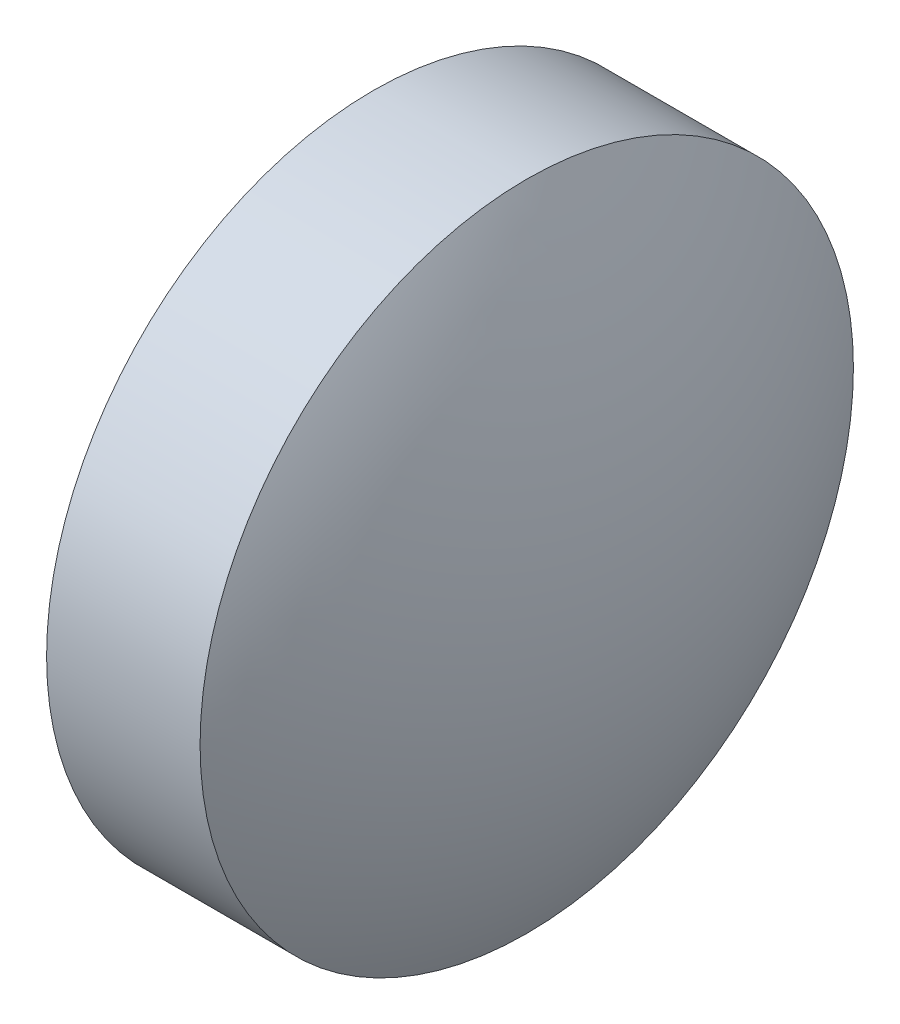
from build123d import *


with BuildPart() as part:
    # 草图1 → 旋转1 (revolve)
    with BuildSketch(Plane.XY):
        with BuildLine():
            Line((510.993207581, 162.592259458), (510.993207581, 165.742259458))
            Line((510.993207581, 165.742259458), (512.473207581, 165.742259458))
            ThreePointArc((512.473207581, 165.742259458), (513.08484753, 164.219749857), (513.293207581, 162.592259458))
            Line((513.293207581, 162.592259458), (510.993207581, 162.592259458))
        make_face()
    revolve(axis=Axis((492.776627745, 162.592259458, 0), (1, 0, 0)))


solid = part.part
